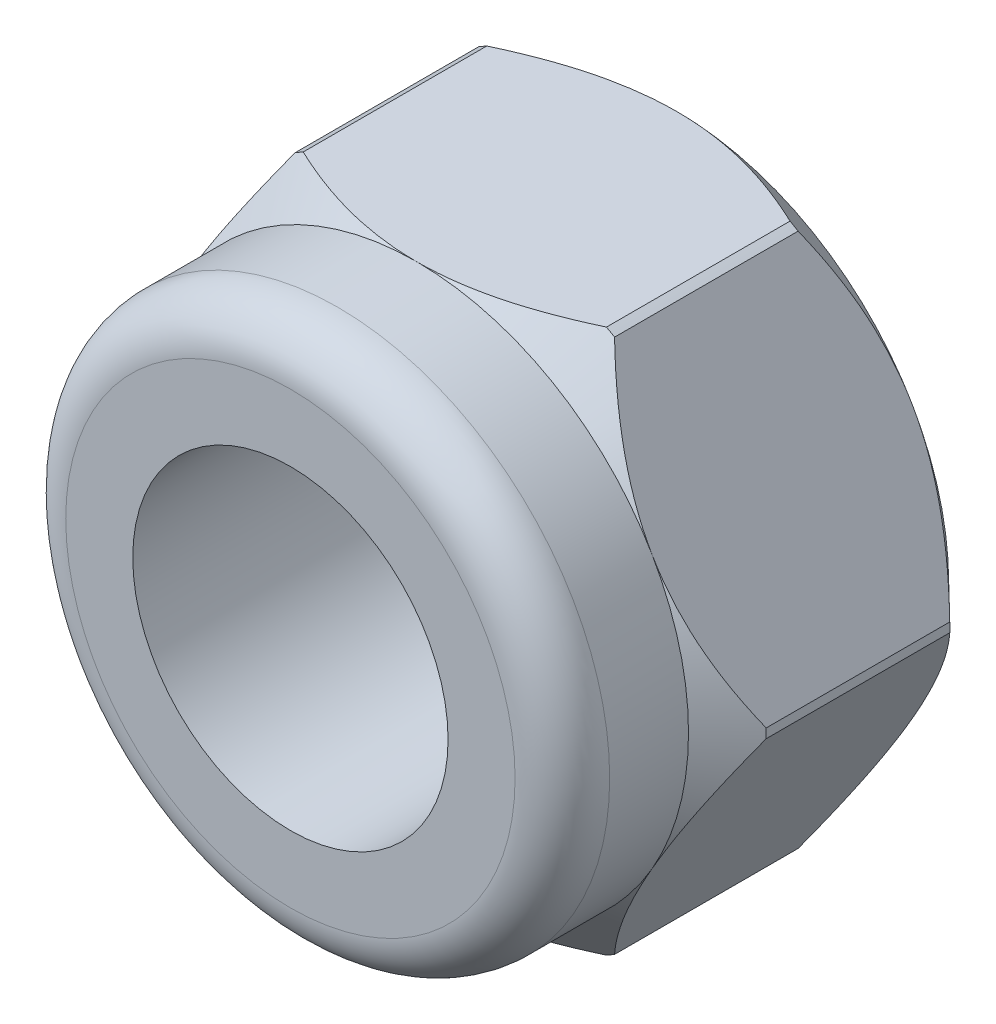
from build123d import *

# Parameters (mm, degrees)
SKETCH1_R           = 2
BOSS_EXTRUDE1_DEPTH = 3.3
SKETCH2_R           = 3.45
SKETCH2_R_2         = 2
BOSS_EXTRUDE2_DEPTH = 1.6
FILLET1_R           = 0.6
CHAMFER1_SIZE       = 0.3


with BuildPart() as part:
    # Sketch1 → Boss-Extrude1 (new body)
    with BuildSketch(Plane.XY):
        Polygon((-1.991858429, 3.45), (1.991858429, 3.45), (3.983716857, 0), (1.991858429, -3.45), (-1.991858429, -3.45), (-3.983716857, 0), align=None)
        Circle(SKETCH1_R, mode=Mode.SUBTRACT)
    extrude(amount=BOSS_EXTRUDE1_DEPTH)

    # Sketch2 → Boss-Extrude2 (add)
    with BuildSketch(Plane.XY.offset(3.3)):
        Circle(SKETCH2_R)
        Circle(SKETCH2_R_2, mode=Mode.SUBTRACT)
    extrude(amount=BOSS_EXTRUDE2_DEPTH)

    # Fillet1
    fillet1_edges = [part.edges().sort_by_distance(p)[0] for p in [
        (-3.45, 0, 4.9),
    ]]
    fillet(fillet1_edges, radius=FILLET1_R)

    # Sketch3 → Cut-Revolve1 (revolve, cut)
    with BuildSketch(Plane(origin=(0, 0, 0), x_dir=(0, 0, -1), z_dir=(1, 0, 0))):
        Polygon((-3.3, 3.45), (-2.814276913, 3.95), (-0.485723087, 3.95), (0, 3.45), (0, 4.719262328), (-3.3, 4.719262328), align=None)
    revolve(axis=Axis((0, 0, 0), (0, 0, -1)), mode=Mode.SUBTRACT)

    # Chamfer1
    chamfer1_edges = [part.edges().sort_by_distance(p)[0] for p in [
        (-2, 0, 0),
    ]]
    chamfer(chamfer1_edges, length=CHAMFER1_SIZE)


solid = part.part
